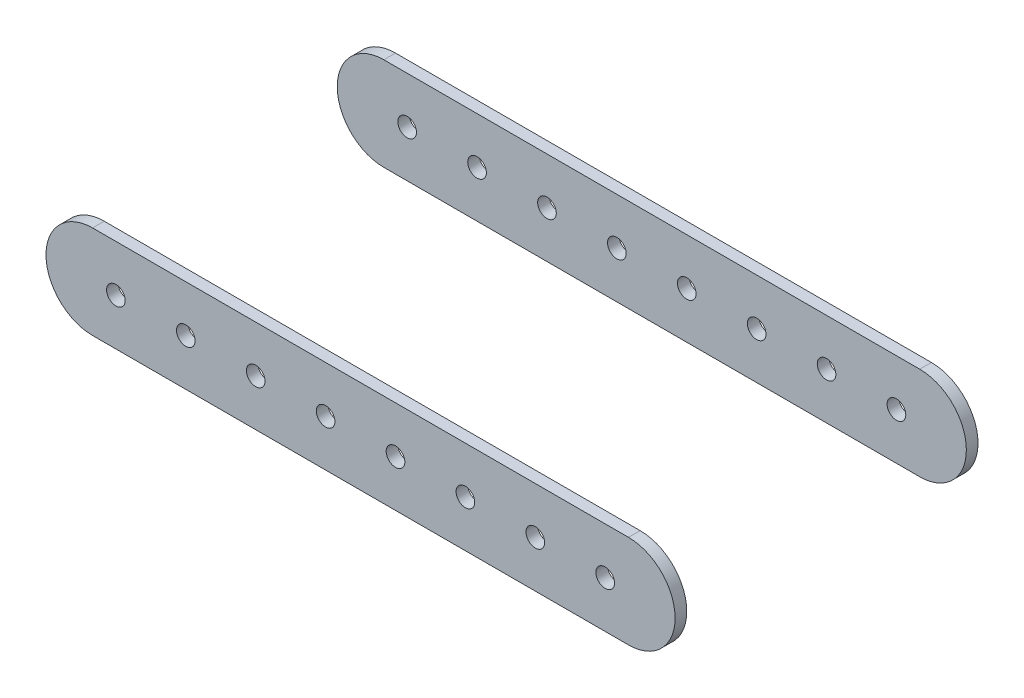
from build123d import *

# Parameters (mm, degrees)
SKETCH2_R               = 4
BOSS_EXTRUDE1_DEPTH     = 5
SKETCH3_R               = 4
CUT_EXTRUDE1_DEPTH      = 66
CUT_EXTRUDE1_DEPTH_BACK = 66


with BuildPart() as part:
    # Sketch2 → Boss-Extrude1 (new body)
    with BuildSketch(Plane.XY.offset(60)):
        with BuildLine():
            Line((-10, 20), (220, 20))
            ThreePointArc((220, 20), (240, 0), (220, -20))
            Line((220, -20), (-10, -20))
            ThreePointArc((-10, -20), (-30, 0), (-10, 20))
        make_face()
        Circle(SKETCH2_R, mode=Mode.SUBTRACT)
        with Locations((210, 0)):
            Circle(SKETCH2_R, mode=Mode.SUBTRACT)
    extrude(amount=BOSS_EXTRUDE1_DEPTH)


with BuildPart() as body_2:
    # Mirror5: mirrored copy
    add(part.part.mirror(Plane.XY))


with BuildPart() as cut_extrude1_tool:
    # Sketch3 → Cut-Extrude1 (new body, two sides)
    with BuildSketch(Plane.XY) as cut_extrude1_sk:
        with Locations((210, 0)):
            Circle(SKETCH3_R)
        with Locations((180, 0)):
            Circle(SKETCH3_R)
        with Locations((150, 0)):
            Circle(SKETCH3_R)
        with Locations((120, 0)):
            Circle(SKETCH3_R)
        with Locations((90, 0)):
            Circle(SKETCH3_R)
        with Locations((60, 0)):
            Circle(SKETCH3_R)
        with Locations((30, 0)):
            Circle(SKETCH3_R)
        Circle(SKETCH3_R)
    extrude(amount=CUT_EXTRUDE1_DEPTH)
    extrude(cut_extrude1_sk.sketch, amount=-CUT_EXTRUDE1_DEPTH_BACK)


with BuildPart() as part_1:
    add(part.part)

    # Cut-Extrude1: cut by cut_extrude1_tool
    add(cut_extrude1_tool.part, mode=Mode.SUBTRACT)


with BuildPart() as body_2_1:
    add(body_2.part)

    # Cut-Extrude1: cut by cut_extrude1_tool
    add(cut_extrude1_tool.part, mode=Mode.SUBTRACT)


solid = Compound([part_1.part, body_2_1.part])
